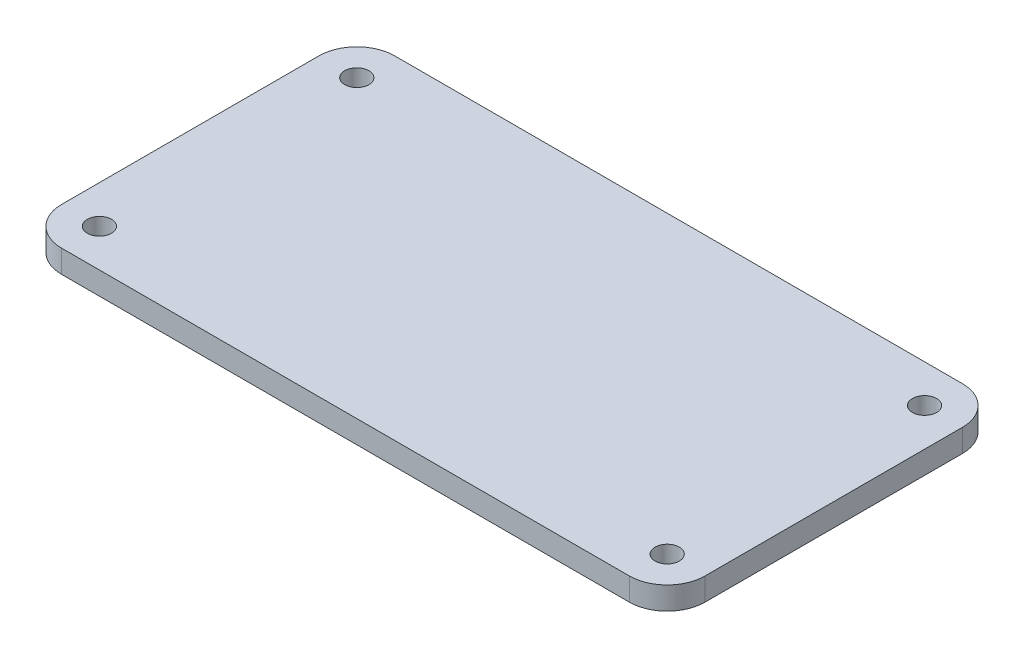
from build123d import *

# Parameters (mm, degrees)
SKETCH_1_W          = 85
SKETCH_1_H          = 44
EXTRUDE_1_DEPTH     = 3
SKETCH_2_R          = 1.6
CUT_EXTRUDE_1_DEPTH = 4
FILLET_1_R          = 5


with BuildPart() as part:
    # 草图1 → 凸台-拉伸1 (new body)
    with BuildSketch(Plane(origin=(0, 0, 0), x_dir=(1, 0, 0), z_dir=(0, 1, 0))):
        Rectangle(SKETCH_1_W, SKETCH_1_H)
    extrude(amount=EXTRUDE_1_DEPTH)

    # 草图2 → 切除-拉伸1 (cut, through all)
    with BuildSketch(Plane(origin=(0, 3, 0), x_dir=(1, 0, 0), z_dir=(0, 1, 0))):
        with Locations((-37.5, 17)):
            Circle(SKETCH_2_R)
        with Locations((-37.5, -17)):
            Circle(SKETCH_2_R)
        with Locations((37.5, 17)):
            Circle(SKETCH_2_R)
        with Locations((37.5, -17)):
            Circle(SKETCH_2_R)
    extrude(amount=-CUT_EXTRUDE_1_DEPTH, mode=Mode.SUBTRACT)

    # 圆角1
    fillet_1_edges = [part.edges().sort_by_distance(p)[0] for p in [
        (-42.5, 1.5, -22),
        (42.5, 1.5, -22),
        (42.5, 1.5, 22),
        (-42.5, 1.5, 22),
    ]]
    fillet(fillet_1_edges, radius=FILLET_1_R)


solid = part.part
